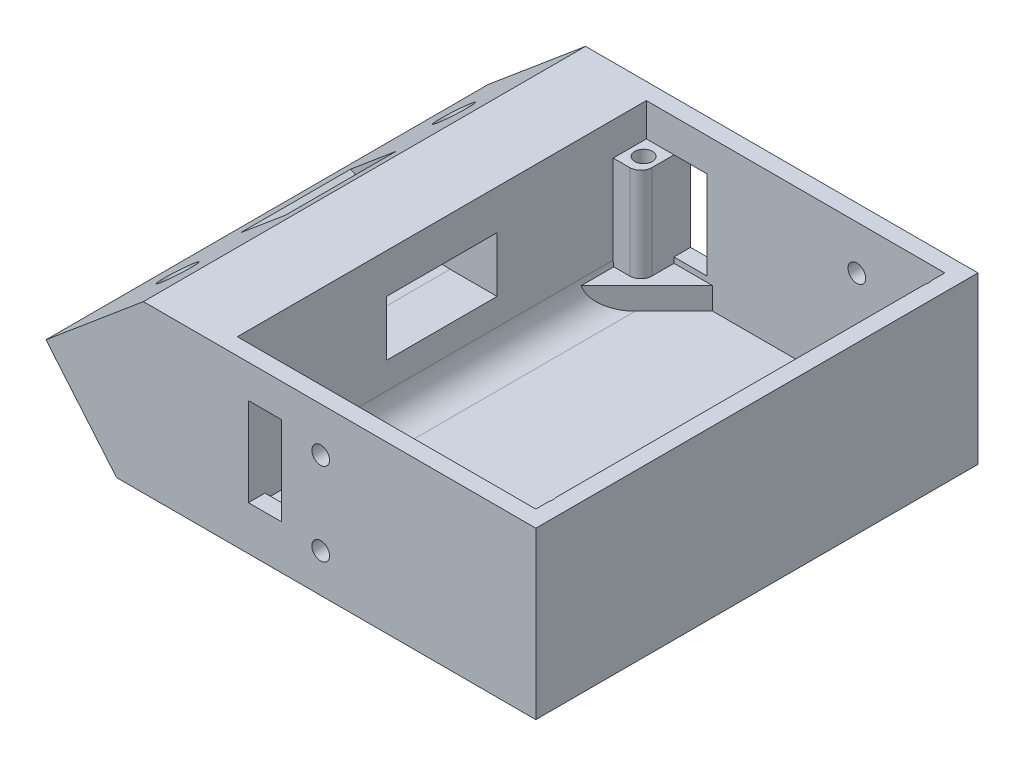
from build123d import *

# Parameters (mm, degrees)
SKETCH1_W                = 61
SKETCH1_H                = 80
BOSS_EXTRUDE1_DEPTH      = 30
SKETCH2_W                = 54
SKETCH2_H                = 74
CUT_EXTRUDE1_DEPTH       = 27
BOSS_EXTRUDE3_DEPTH      = 80
BOSS_EXTRUDE2_DEPTH      = 4
SKETCH5_R                = 1.6
CUT_EXTRUDE3_DEPTH       = 31
CUT_EXTRUDE4_DEPTH       = 3
CUT_EXTRUDE6_DEPTH       = 81
SKETCH16_R               = 3.1
CUT_EXTRUDE8_DEPTH       = 69.619253581
FILLET1_R                = 5
CUT_EXTRUDE9_START       = -25
SKETCH17_R               = 6.5
CUT_EXTRUDE9_DEPTH       = 10
CUT_EXTRUDE10_START      = -30
CUT_EXTRUDE10_DEPTH      = 20
FILLET2_R                = 20
CUT_EXTRUDE11_REACH      = 82
SKETCH19_R               = 1.6
SKETCH20_W               = 6
SKETCH20_H               = 16
CUT_EXTRUDE12_DEPTH      = 78
CUT_EXTRUDE12_DEPTH_BACK = 4
SKETCH21_W               = 5
SKETCH21_H               = 6
SKETCH21_R               = 1.6
SKETCH21_W_2             = 6
BOSS_EXTRUDE4_DEPTH      = 17
FILLET4_R                = 2
CUT_EXTRUDE13_START      = -77
SKETCH22_R               = 1.6
CUT_EXTRUDE13_DEPTH      = 4


with BuildPart() as part:
    # Sketch1 → Boss-Extrude1 (new body)
    with BuildSketch(Plane(origin=(0, 0, 0), x_dir=(1, 0, 0), z_dir=(0, 1, 0))):
        Rectangle(SKETCH1_W, SKETCH1_H)
    extrude(amount=BOSS_EXTRUDE1_DEPTH)

    # Sketch2 → Cut-Extrude1 (cut)
    with BuildSketch(Plane(origin=(0, 30, 0), x_dir=(1, 0, 0), z_dir=(0, 1, 0))):
        with Locations((0.5, 0)):
            Rectangle(SKETCH2_W, SKETCH2_H)
    extrude(amount=-CUT_EXTRUDE1_DEPTH, mode=Mode.SUBTRACT)

    # Sketch11 → Boss-Extrude3 (add)
    with BuildSketch(Plane.XY.offset(40)):
        Polygon((-30.5, 30), (-40.5, 30), (-58.119022192, 15.215884977), (-58.119022192, 0), (-30.5, 0), align=None)
    extrude(amount=-BOSS_EXTRUDE3_DEPTH)

    # Sketch7 → Boss-Extrude2 (add)
    with BuildSketch(Plane(origin=(0, 3, 0), x_dir=(1, 0, 0), z_dir=(0, 1, 0))):
        Polygon((27.5, -25), (15.5, -37), (27.5, -37), align=None)
        Polygon((27.5, 25), (15.5, 37), (27.5, 37), align=None)
        Polygon((-26.5, 25), (-14.5, 37), (-26.5, 37), align=None)
        Polygon((-14.5, -37), (-26.5, -25), (-26.5, -37), align=None)
    extrude(amount=BOSS_EXTRUDE2_DEPTH)

    # Sketch5 → Cut-Extrude3 (cut, through all)
    with BuildSketch(Plane.XZ):
        with Locations((-24, -34)):
            Circle(SKETCH5_R)
        with Locations((-24, 34)):
            Circle(SKETCH5_R)
        with Locations((26, 34)):
            Circle(SKETCH5_R)
        with Locations((26, -34)):
            Circle(SKETCH5_R)
    extrude(amount=-CUT_EXTRUDE3_DEPTH, mode=Mode.SUBTRACT)

    # Sketch8 → Cut-Extrude4 (cut)
    with BuildSketch(Plane.XZ):
        Polygon((-25.625, 36.814582562), (-27.25, 34), (-25.625, 31.185417438), (-22.375, 31.185417438), (-20.75, 34), (-22.375, 36.814582562), align=None)
        Polygon((24.375, 36.814582562), (22.75, 34), (24.375, 31.185417438), (27.625, 31.185417438), (29.25, 34), (27.625, 36.814582562), align=None)
        Polygon((-25.625, -31.185417438), (-27.25, -34), (-25.625, -36.814582562), (-22.375, -36.814582562), (-20.75, -34), (-22.375, -31.185417438), align=None)
        Polygon((24.375, -31.185417438), (22.75, -34), (24.375, -36.814582562), (27.625, -36.814582562), (29.25, -34), (27.625, -31.185417438), align=None)
    extrude(amount=-CUT_EXTRUDE4_DEPTH, mode=Mode.SUBTRACT)

    # Sketch12 → Cut-Extrude6 (cut, through all)
    with BuildSketch(Plane.XY.offset(40)):
        Polygon((-58.119022192, 15.215884977), (-45.351378719, 0), (-58.119022192, 0), align=None)
    extrude(amount=-CUT_EXTRUDE6_DEPTH, mode=Mode.SUBTRACT)

    # Sketch16 → Cut-Extrude8 (cut, through all)
    with BuildSketch(Plane(origin=(-31.505740697, 37.547079664, 0), x_dir=(0.766044443, 0.64278761, 0), z_dir=(-0.64278761, 0.766044443, 0))):
        with Locations((-23.241171656, 25)):
            Circle(SKETCH16_R)
        with Locations((-23.241171656, -25)):
            Circle(SKETCH16_R)
    extrude(amount=-CUT_EXTRUDE8_DEPTH, mode=Mode.SUBTRACT)

    # Fillet1
    fillet1_edges = [part.edges().sort_by_distance(p)[0] for p in [
        (-26.5, 3, 0),
    ]]
    fillet(fillet1_edges, radius=FILLET1_R)

    # Sketch17 → Cut-Extrude9 (cut)
    with BuildSketch(Plane(origin=(-31.505740697, 37.547079664, 0), x_dir=(0.766044443, 0.64278761, 0), z_dir=(-0.64278761, 0.766044443, 0)).offset(CUT_EXTRUDE9_START)):
        with Locations((-23.241171656, -25)):
            Circle(SKETCH17_R)
        with Locations((-23.241171656, 25)):
            Circle(SKETCH17_R)
    extrude(amount=-CUT_EXTRUDE9_DEPTH, mode=Mode.SUBTRACT)

    # Sketch18 → Cut-Extrude10 (cut)
    with BuildSketch(Plane.XY.offset(40).offset(CUT_EXTRUDE10_START)):
        Polygon((-44.812844495, 26.381093775), (-37.803211847, 22.814854282), (-23.803211847, 22.814854282), (-23.803211847, 12.814854282), (-39.803211847, 12.814854282), (-52.986917817, 19.522231865), align=None)
    extrude(amount=-CUT_EXTRUDE10_DEPTH, mode=Mode.SUBTRACT)

    # Fillet2
    fillet2_edges = [part.edges().sort_by_distance(p)[0] for p in [
        (-37.803211847, 22.814854282, 0),
        (-39.803211847, 12.814854282, 0),
    ]]
    fillet(fillet2_edges, radius=FILLET2_R)

    # Sketch19 → Cut-Extrude11 (cut, up to next)
    with BuildSketch(Plane.XY.offset(40), mode=Mode.PRIVATE) as cut_extrude11_sk1:
        with Locations((-8.416221869, 22)):
            Circle(SKETCH19_R)
    cut_extrude11_tool1 = extrude(cut_extrude11_sk1.sketch, amount=-CUT_EXTRUDE11_REACH, mode=Mode.PRIVATE) & part.part
    add(cut_extrude11_tool1.solids().sort_by_distance((-8.416222, 22, 40))[0], mode=Mode.SUBTRACT)
    # Sketch19 → Cut-Extrude11 (cut, up to next)
    with BuildSketch(Plane.XY.offset(40), mode=Mode.PRIVATE) as cut_extrude11_sk2:
        with Locations((-8.416221869, 7)):
            Circle(SKETCH19_R)
    cut_extrude11_tool2 = extrude(cut_extrude11_sk2.sketch, amount=-CUT_EXTRUDE11_REACH, mode=Mode.PRIVATE) & part.part
    add(cut_extrude11_tool2.solids().sort_by_distance((-8.416222, 7, 40))[0], mode=Mode.SUBTRACT)

    # Sketch20 → Cut-Extrude12 (cut, two sides)
    with BuildSketch(Plane(origin=(0, 0, 37), x_dir=(-1, 0, 0), z_dir=(0, 0, -1))) as cut_extrude12_sk:
        with Locations((18.5, 16)):
            Rectangle(SKETCH20_W, SKETCH20_H)
    extrude(amount=CUT_EXTRUDE12_DEPTH, mode=Mode.SUBTRACT)
    extrude(cut_extrude12_sk.sketch, amount=-CUT_EXTRUDE12_DEPTH_BACK, mode=Mode.SUBTRACT)

    # Sketch21 → Boss-Extrude4 (add)
    with BuildSketch(Plane(origin=(0, 7, 0), x_dir=(1, 0, 0), z_dir=(0, 1, 0))):
        with Locations((-24, -34)):
            Rectangle(SKETCH21_W, SKETCH21_H)
        with Locations((-24, -34)):
            Circle(SKETCH21_R, mode=Mode.SUBTRACT)
        with Locations((-24, 34)):
            Rectangle(SKETCH21_W, SKETCH21_H)
        with Locations((-24, 34)):
            Circle(SKETCH21_R, mode=Mode.SUBTRACT)
        with Locations((26, 34)):
            Rectangle(SKETCH21_W_2, SKETCH21_H)
        with Locations((26, 34)):
            Circle(SKETCH21_R, mode=Mode.SUBTRACT)
        with Locations((26, -34)):
            Rectangle(SKETCH21_W_2, SKETCH21_H)
        with Locations((26, -34)):
            Circle(SKETCH21_R, mode=Mode.SUBTRACT)
    extrude(amount=BOSS_EXTRUDE4_DEPTH)

    # Fillet4
    fillet4_edges = [part.edges().sort_by_distance(p)[0] for p in [
        (-21.5, 15.5, 31),
        (-21.5, 15.5, -31),
        (23, 15.5, -31),
        (23, 15.5, 31),
    ]]
    fillet(fillet4_edges, radius=FILLET4_R)

    # Sketch22 → Cut-Extrude13 (cut, through all)
    with BuildSketch(Plane.XY.offset(40).offset(CUT_EXTRUDE13_START)):
        with Locations((11.583778131, 22)):
            Circle(SKETCH22_R)
        with Locations((11.583778131, 7)):
            Circle(SKETCH22_R)
    extrude(amount=-CUT_EXTRUDE13_DEPTH, mode=Mode.SUBTRACT)


solid = part.part
